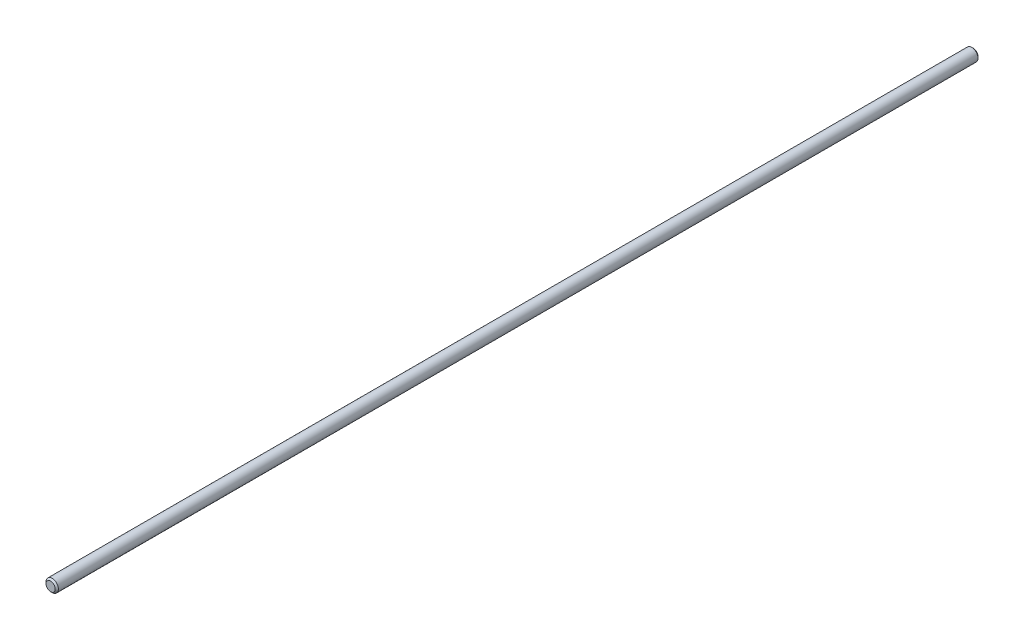
from build123d import *

# Parameters (mm, degrees)
SKETCH1_R           = 2
BOSS_EXTRUDE1_DEPTH = 298.45
CHAMFER1_SIZE       = 0.508


with BuildPart() as part:
    # Sketch1 → Boss-Extrude1 (new body)
    with BuildSketch(Plane.XY):
        Circle(SKETCH1_R)
    extrude(amount=BOSS_EXTRUDE1_DEPTH)

    # Chamfer1
    chamfer1_edges = [part.edges().sort_by_distance(p)[0] for p in [
        (-2, 0, 0),
        (-2, 0, 298.45),
    ]]
    chamfer(chamfer1_edges, length=CHAMFER1_SIZE)


solid = part.part
